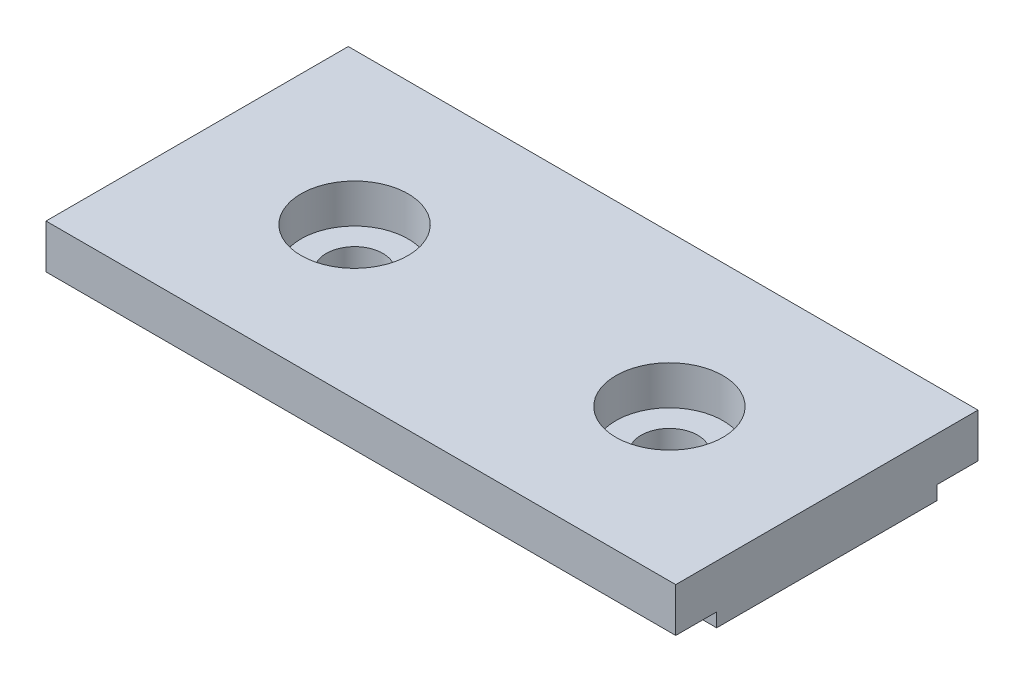
from build123d import *

# Parameters (mm, degrees)
BOSS_EXTRU_1_DEPTH                                 = 50
CHAMBRAGE_POUR_VIS_T_TE_HEXAGONALE_M42_D           = 4.5
CHAMBRAGE_POUR_VIS_T_TE_HEXAGONALE_M42_CBORE_D     = 8.5
CHAMBRAGE_POUR_VIS_T_TE_HEXAGONALE_M42_CBORE_DEPTH = 3.1


with BuildPart() as part:
    # Esquisse2 → Boss.-Extru.1 (new body)
    with BuildSketch(Plane(origin=(0, 0, 0), x_dir=(0, 0, -1), z_dir=(1, 0, 0))):
        Polygon((-12, 6.945454545), (12, 6.945454545), (12, 3.445454545), (8.75, 3.445454545), (8.75, 2.345454545), (-8.75, 2.345454545), (-8.75, 3.445454545), (-12, 3.445454545), align=None)
    extrude(amount=BOSS_EXTRU_1_DEPTH)

    # Chambrage pour vis à tête hexagonale M42 (through all)
    with Locations(Plane(origin=(12.5, 6.945454545, 0), x_dir=(0, 0, 1), z_dir=(0, 1, 0))):
        with Locations((0, 0), (0, 25)):
            CounterBoreHole(CHAMBRAGE_POUR_VIS_T_TE_HEXAGONALE_M42_D / 2, CHAMBRAGE_POUR_VIS_T_TE_HEXAGONALE_M42_CBORE_D / 2, CHAMBRAGE_POUR_VIS_T_TE_HEXAGONALE_M42_CBORE_DEPTH)


solid = part.part
